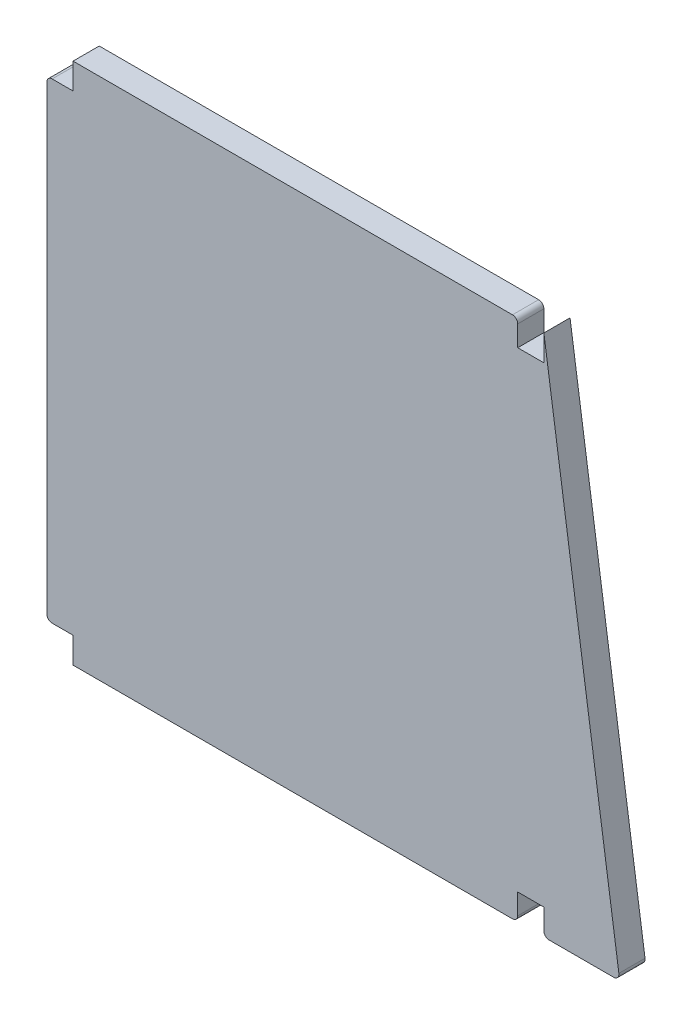
from build123d import *

# Parameters (mm, degrees)
BOSS_EXTRUDE1_DEPTH = 5
FILLET1_R           = 1


with BuildPart() as part:
    # Sketch1 → Boss-Extrude1 (new body)
    with BuildSketch(Plane.XY):
        Polygon((0, 95.05), (0, 100), (85, 100), (85, 95.05), (90, 95.05), (90, 100), (104.5, 0), (90, 0), (90, 4.95), (85, 4.95), (85, 0), (0, 0), (0, 4.95), (-5, 4.95), (-5, 95.05), align=None)
    extrude(amount=BOSS_EXTRUDE1_DEPTH)

    # Fillet1
    fillet1_edges = [part.edges().sort_by_distance(p)[0] for p in [
        (-5, 4.95, 2.5),
        (-5, 95.05, 2.5),
        (85, 100, 2.5),
        (104.5, 0, 2.5),
        (90, 0, 2.5),
        (85, 0, 2.5),
    ]]
    fillet(fillet1_edges, radius=FILLET1_R)


solid = part.part
